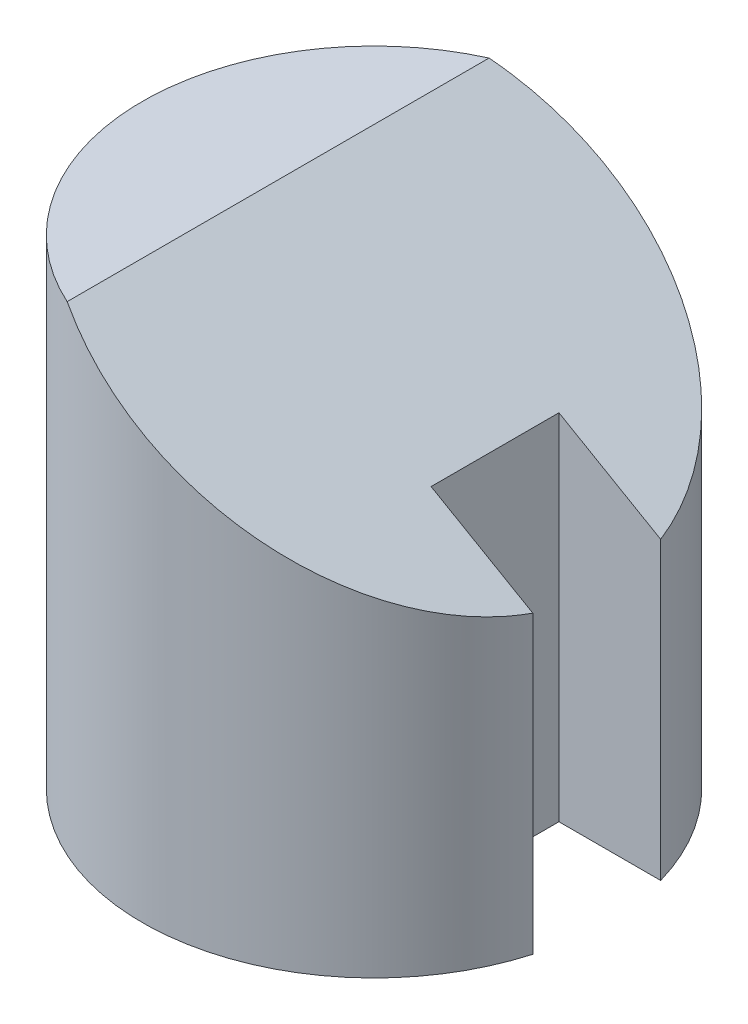
from build123d import *

# Parameters (mm, degrees)
SKETCH1_R               = 29
BOSS_EXTRUDE1_DEPTH     = 60
CUT_EXTRUDE1_DEPTH      = 30
CUT_EXTRUDE1_DEPTH_BACK = 30
CUT_EXTRUDE2_DEPTH      = 70.969655115


with BuildPart() as part:
    # Sketch1 → Boss-Extrude1 (new body)
    with BuildSketch(Plane(origin=(0, 0, 0), x_dir=(1, 0, 0), z_dir=(0, 1, 0))):
        Circle(SKETCH1_R)
    extrude(amount=BOSS_EXTRUDE1_DEPTH)

    # Sketch2 → Cut-Extrude1 (cut, two sides)
    with BuildSketch(Plane.XY) as cut_extrude1_sk:
        Polygon((-12, 60), (29, 36.328638963), (29, 60), align=None)
    extrude(amount=CUT_EXTRUDE1_DEPTH, mode=Mode.SUBTRACT)
    extrude(cut_extrude1_sk.sketch, amount=-CUT_EXTRUDE1_DEPTH_BACK, mode=Mode.SUBTRACT)

    # Sketch7 → Cut-Extrude2 (cut, through all, along a direction that is not the sketch's normal)
    with BuildSketch(Plane(origin=(22.980762114, 39.803847577, 0), x_dir=(0.866025404, -0.5, 0), z_dir=(0.5, 0.866025404, 0))):
        with BuildLine():
            Line((5.651055494, 8), (-9.049582772, 8))
            Line((-9.049582772, 8), (-9.049582772, -8))
            Line((-9.049582772, -8), (5.651055494, -8))
            ThreePointArc((5.651055494, -8), (6.950417228, 0), (5.651055494, 8))
        make_face()
    extrude(amount=-CUT_EXTRUDE2_DEPTH, dir=(0, 1, 0), mode=Mode.SUBTRACT)


solid = part.part
